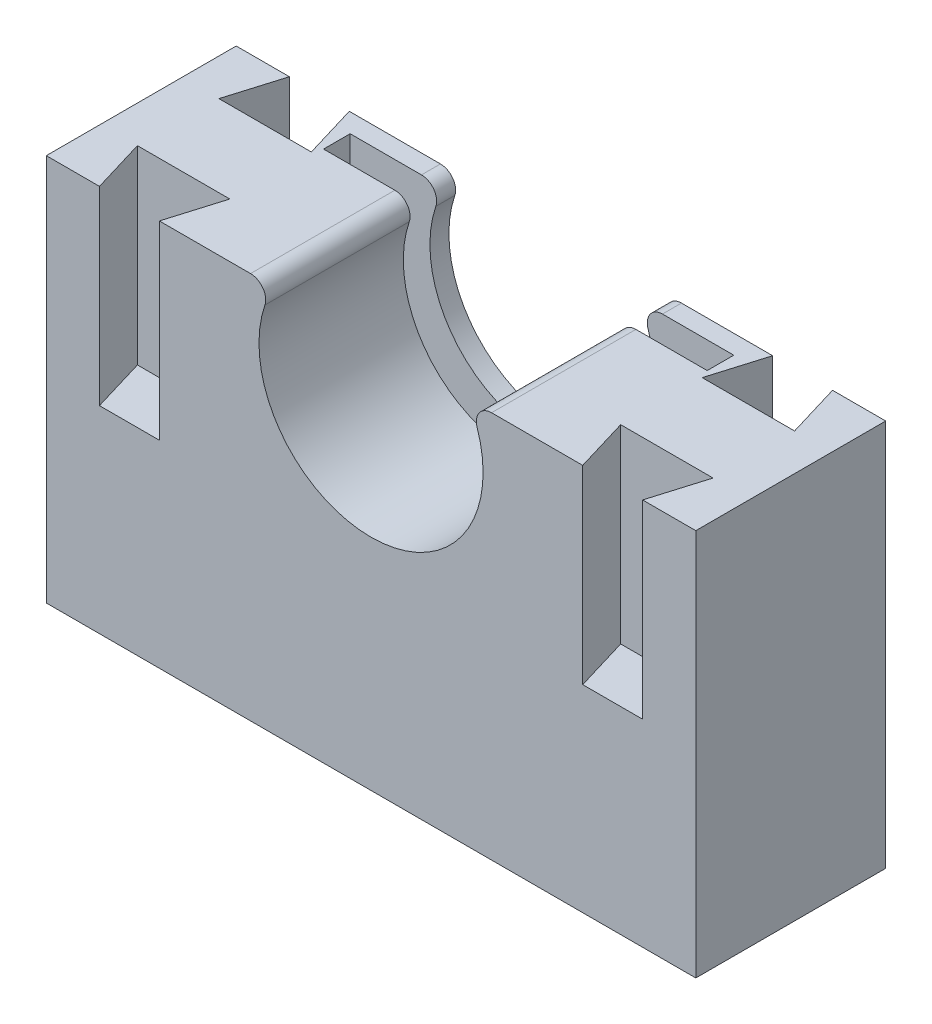
from build123d import *

# Parameters (mm, degrees)
BOSS_EXTRUDE1_DEPTH = 25
CUT_EXTRUDE3_START  = -25
SKETCH5_R           = 4.4
CUT_EXTRUDE3_DEPTH  = 4.8
SKETCH6_OUTSIDE_W   = 108.03
SKETCH6_OUTSIDE_H   = 47.53
CUT_EXTRUDE4_DEPTH  = 25
SKETCH8_W           = 50.5
SKETCH8_H           = 25.070079704
CUT_EXTRUDE5_DEPTH  = 3.5


with BuildPart() as part:
    # Sketch2 → Boss-Extrude1 (new body)
    with BuildSketch(Plane.XY):
        with BuildLine():
            Line((53.900497512, 28.014925373), (27.014667046, 28.014925373))
            ThreePointArc((27.014667046, 28.014925373), (25.389308303, 27.180347595), (25.120437848, 25.373134328))
            ThreePointArc((25.120437848, 25.373134328), (11.150497512, 5.889925373), (-2.819442823, 25.373134328))
            ThreePointArc((-2.819442823, 25.373134328), (-3.088313278, 27.180347595), (-4.713672021, 28.014925373))
            Line((-4.713672021, 28.014925373), (-31.599502488, 28.014925373))
            Line((-31.599502488, 28.014925373), (-31.599502488, -22.985074627))
            Line((-31.599502488, -22.985074627), (53.900497512, -22.985074627))
            Line((53.900497512, -22.985074627), (53.900497512, 28.014925373))
        make_face()
    extrude(amount=BOSS_EXTRUDE1_DEPTH)

    # Sketch5 → Cut-Extrude3 (cut)
    with BuildSketch(Plane.XY.offset(25).offset(CUT_EXTRUDE3_START)):
        with Locations((11.150497512, -2.910074627)):
            Circle(SKETCH5_R)
    extrude(amount=CUT_EXTRUDE3_DEPTH, mode=Mode.SUBTRACT)

    # Sketch6 outside → Cut-Extrude4 (cut)
    with BuildSketch(Plane(origin=(0, 28.014925373, 0), x_dir=(1, 0, 0), z_dir=(0, 1, 0))):
        with Locations((11.15, -12.5)):
            Rectangle(SKETCH6_OUTSIDE_W, SKETCH6_OUTSIDE_H)
        Polygon((-24.599502488, 0), (-26.73851519, -7.13632431), (-14.574659319, -7.13632431), (-16.713672021, 0), (-4.713672021, 0), (27.014667046, 0), (39.014667046, 0), (36.875076634, -7.136151124), (49.040087925, -7.136151124), (46.900497512, 0), (53.900497512, 0), (53.900497512, -25), (46.900497512, -25), (49.040087925, -17.863848876), (36.875076634, -17.863848876), (39.014667046, -25), (27.014667046, -25), (-4.713672021, -25), (-16.713672021, -25), (-14.574081609, -17.863848876), (-26.7390929, -17.863848876), (-24.599502488, -25), (-31.599502488, -25), (-31.599502488, 0), align=None, mode=Mode.SUBTRACT)
    extrude(amount=-CUT_EXTRUDE4_DEPTH, mode=Mode.SUBTRACT)

    # Sketch8 → Cut-Extrude5 (cut)
    with BuildSketch(Plane(origin=(0, 0, 2.5), x_dir=(-1, 0, 0), z_dir=(0, 0, -1))):
        with Locations((-11.150497512, 15.479885521)):
            Rectangle(SKETCH8_W, SKETCH8_H)
    extrude(amount=-CUT_EXTRUDE5_DEPTH, mode=Mode.SUBTRACT)


solid = part.part
